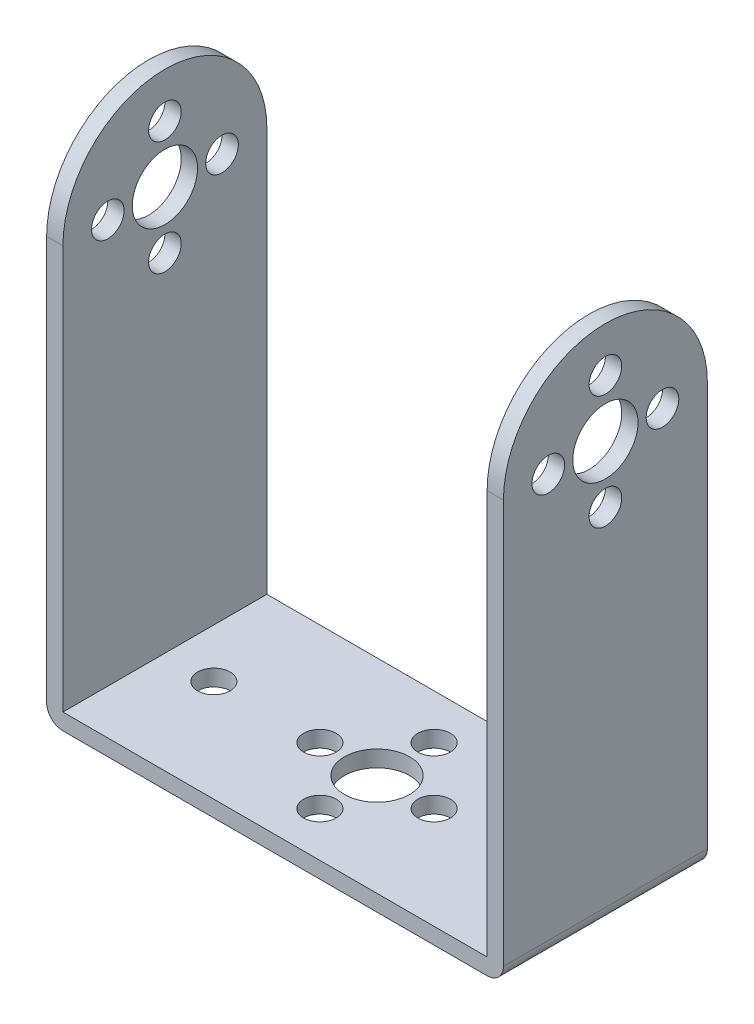
from build123d import *

# Parameters (mm, degrees)
SKETCH_2_R          = 4
SKETCH_2_R_2        = 2
EXTRUDE_1_DEPTH     = 56
CUT_EXTRUDE_1_REACH = 27
SKETCH_3_W          = 52
SKETCH_3_H          = 64
CUT_EXTRUDE_2_REACH = 4
SKETCH_4_R          = 4
SKETCH_4_R_2        = 2
FILLET_1_R          = 2
FILLET_2_R          = 2


with BuildPart() as part:
    # 草图2 → 凸台-拉伸1 (new body)
    with BuildSketch(Plane(origin=(0, 0, 0), x_dir=(0, 0, -1), z_dir=(1, 0, 0))):
        with BuildLine():
            Line((-23.249580799, 25.750000985), (-23.249580799, -25.75))
            Line((-23.249580799, -25.75), (1.750419201, -25.75))
            Line((1.750419201, -25.75), (1.750419201, 25.75))
            ThreePointArc((1.750419201, 25.75), (-10.749580306, 38.250000985), (-23.249580799, 25.750000985))
        make_face()
        with Locations((-10.749580799, 25.750000985)):
            Circle(SKETCH_2_R, mode=Mode.SUBTRACT)
        with Locations((-10.749580799, 32.750000985)):
            Circle(SKETCH_2_R_2, mode=Mode.SUBTRACT)
        with Locations((-17.749579814, 25.75000197)):
            Circle(SKETCH_2_R_2, mode=Mode.SUBTRACT)
        with Locations((-10.749580799, 18.750002956)):
            Circle(SKETCH_2_R_2, mode=Mode.SUBTRACT)
        with Locations((-3.749581784, 25.75000197)):
            Circle(SKETCH_2_R_2, mode=Mode.SUBTRACT)
    extrude(amount=EXTRUDE_1_DEPTH)

    # 草图3 → 切除-拉伸1 (cut, up to next)
    with BuildSketch(Plane(origin=(0, 0, -1.750419201), x_dir=(-1, 0, 0), z_dir=(0, 0, -1)), mode=Mode.PRIVATE) as cut_extrude_1_sk1:
        with Locations((-28, 8.25)):
            Rectangle(SKETCH_3_W, SKETCH_3_H)
    cut_extrude_1_tool1 = extrude(cut_extrude_1_sk1.sketch, amount=-CUT_EXTRUDE_1_REACH, mode=Mode.PRIVATE) & part.part
    add(cut_extrude_1_tool1.solids().sort_by_distance((28, 8.25, -1.750419))[0], mode=Mode.SUBTRACT)

    # 草图4 → 切除-拉伸2 (cut, up to next)
    with BuildSketch(Plane(origin=(0, -23.75, 0), x_dir=(1, 0, 0), z_dir=(0, 1, 0)), mode=Mode.PRIVATE) as cut_extrude_2_sk1:
        with Locations((28, -10.749580799)):
            Circle(SKETCH_4_R)
    cut_extrude_2_tool1 = extrude(cut_extrude_2_sk1.sketch, amount=-CUT_EXTRUDE_2_REACH, mode=Mode.PRIVATE) & part.part
    add(cut_extrude_2_tool1.solids().sort_by_distance((28, -23.75, 10.749581))[0], mode=Mode.SUBTRACT)
    # 草图4 → 切除-拉伸2 (cut, up to next)
    with BuildSketch(Plane(origin=(0, -23.75, 0), x_dir=(1, 0, 0), z_dir=(0, 1, 0)), mode=Mode.PRIVATE) as cut_extrude_2_sk2:
        with Locations((35, -10.749580799)):
            Circle(SKETCH_4_R_2)
    cut_extrude_2_tool2 = extrude(cut_extrude_2_sk2.sketch, amount=-CUT_EXTRUDE_2_REACH, mode=Mode.PRIVATE) & part.part
    add(cut_extrude_2_tool2.solids().sort_by_distance((35, -23.75, 10.749581))[0], mode=Mode.SUBTRACT)
    # 草图4 → 切除-拉伸2 (cut, up to next)
    with BuildSketch(Plane(origin=(0, -23.75, 0), x_dir=(1, 0, 0), z_dir=(0, 1, 0)), mode=Mode.PRIVATE) as cut_extrude_2_sk3:
        with Locations((28, -17.749580799)):
            Circle(SKETCH_4_R_2)
    cut_extrude_2_tool3 = extrude(cut_extrude_2_sk3.sketch, amount=-CUT_EXTRUDE_2_REACH, mode=Mode.PRIVATE) & part.part
    add(cut_extrude_2_tool3.solids().sort_by_distance((28, -23.75, 17.749581))[0], mode=Mode.SUBTRACT)
    # 草图4 → 切除-拉伸2 (cut, up to next)
    with BuildSketch(Plane(origin=(0, -23.75, 0), x_dir=(1, 0, 0), z_dir=(0, 1, 0)), mode=Mode.PRIVATE) as cut_extrude_2_sk4:
        with Locations((21, -10.749580799)):
            Circle(SKETCH_4_R_2)
    cut_extrude_2_tool4 = extrude(cut_extrude_2_sk4.sketch, amount=-CUT_EXTRUDE_2_REACH, mode=Mode.PRIVATE) & part.part
    add(cut_extrude_2_tool4.solids().sort_by_distance((21, -23.75, 10.749581))[0], mode=Mode.SUBTRACT)
    # 草图4 → 切除-拉伸2 (cut, up to next)
    with BuildSketch(Plane(origin=(0, -23.75, 0), x_dir=(1, 0, 0), z_dir=(0, 1, 0)), mode=Mode.PRIVATE) as cut_extrude_2_sk5:
        with Locations((28, -3.749580799)):
            Circle(SKETCH_4_R_2)
    cut_extrude_2_tool5 = extrude(cut_extrude_2_sk5.sketch, amount=-CUT_EXTRUDE_2_REACH, mode=Mode.PRIVATE) & part.part
    add(cut_extrude_2_tool5.solids().sort_by_distance((28, -23.75, 3.749581))[0], mode=Mode.SUBTRACT)
    # 草图4 → 切除-拉伸2 (cut, up to next)
    with BuildSketch(Plane(origin=(0, -23.75, 0), x_dir=(1, 0, 0), z_dir=(0, 1, 0)), mode=Mode.PRIVATE) as cut_extrude_2_sk6:
        with Locations((8, -10.749580799)):
            Circle(SKETCH_4_R_2)
    cut_extrude_2_tool6 = extrude(cut_extrude_2_sk6.sketch, amount=-CUT_EXTRUDE_2_REACH, mode=Mode.PRIVATE) & part.part
    add(cut_extrude_2_tool6.solids().sort_by_distance((8, -23.75, 10.749581))[0], mode=Mode.SUBTRACT)
    # 草图4 → 切除-拉伸2 (cut, up to next)
    with BuildSketch(Plane(origin=(0, -23.75, 0), x_dir=(1, 0, 0), z_dir=(0, 1, 0)), mode=Mode.PRIVATE) as cut_extrude_2_sk7:
        with Locations((48, -10.749580799)):
            Circle(SKETCH_4_R_2)
    cut_extrude_2_tool7 = extrude(cut_extrude_2_sk7.sketch, amount=-CUT_EXTRUDE_2_REACH, mode=Mode.PRIVATE) & part.part
    add(cut_extrude_2_tool7.solids().sort_by_distance((48, -23.75, 10.749581))[0], mode=Mode.SUBTRACT)

    # 圆角1
    fillet_1_edges = [part.edges().sort_by_distance(p)[0] for p in [
        (56, -25.75, 10.749580799),
    ]]
    fillet(fillet_1_edges, radius=FILLET_1_R)

    # 圆角2
    fillet_2_edges = [part.edges().sort_by_distance(p)[0] for p in [
        (0, -25.75, 10.749580799),
    ]]
    fillet(fillet_2_edges, radius=FILLET_2_R)


solid = part.part
